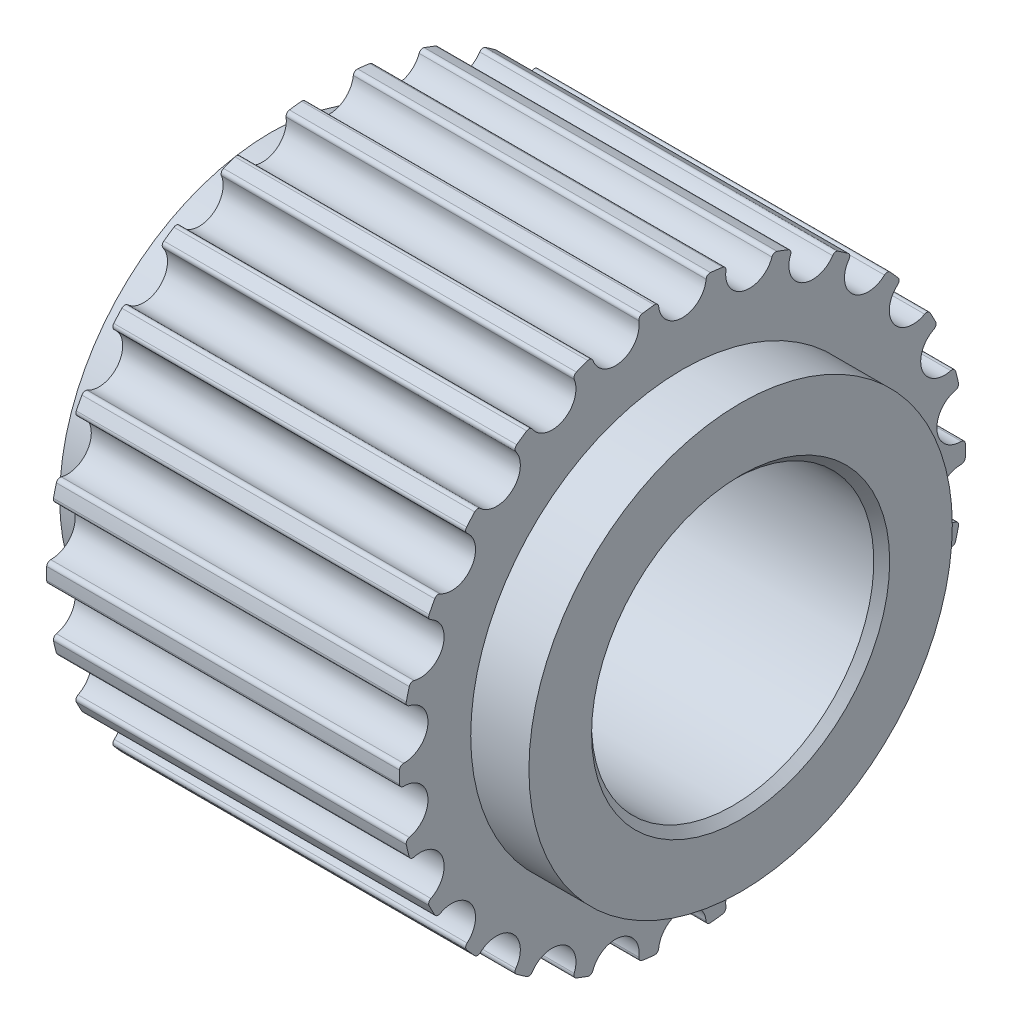
from build123d import *

# Parameters (mm, degrees)
CUT_EXTRUDE1_DEPTH = 12.65
CIRPATTERN1_COUNT  = 26


with BuildPart() as part:
    # Sketch1 → Revolve1 (revolve)
    with BuildSketch(Plane.XY):
        Polygon((-5, 8.02), (5, 8.02), (5, 6), (6.65, 6), (6.65, 4.225), (6.425, 4), (-6.425, 4), (-6.65, 4.225), (-6.65, 6), (-5, 6), align=None)
    revolve(axis=Axis((17.85, 0, 0), (-1, 0, 0)))

    # Sketch5 → Cut-Extrude1 (cut, through all)
    with BuildSketch(Plane(origin=(-5, 0, -21.5), x_dir=(0, 0, 1), z_dir=(-1, 0, 0))):
        with BuildLine():
            Line((19, 7.620393691), (19, 7.888322065))
            ThreePointArc((19, 7.888322065), (21.5, 8.275), (24, 7.888322065))
            Line((24, 7.888322065), (24, 7.620393691))
            ThreePointArc((24, 7.620393691), (23.15727635, 7.846899713), (22.294932233, 7.980506422))
            ThreePointArc((22.294932233, 7.980506422), (22.212418714, 7.955529493), (22.171812608, 7.879480351))
            ThreePointArc((22.171812608, 7.879480351), (21.5, 7.26999997), (20.828187392, 7.879480351))
            ThreePointArc((20.828187392, 7.879480351), (20.787581286, 7.955529493), (20.705067767, 7.980506422))
            ThreePointArc((20.705067767, 7.980506422), (19.84272365, 7.846899713), (19, 7.620393691))
        make_face()
    cut_extrude1 = extrude(amount=-CUT_EXTRUDE1_DEPTH, mode=Mode.SUBTRACT)

    # CirPattern1: Cut-Extrude1 ×26 about axis
    cirpattern1_axis = Axis((0, 0, 0), (1, 0, 0))
    for i in range(1, CIRPATTERN1_COUNT):
        add(cut_extrude1.rotate(cirpattern1_axis, i * 360 / CIRPATTERN1_COUNT), mode=Mode.SUBTRACT)


solid = part.part
